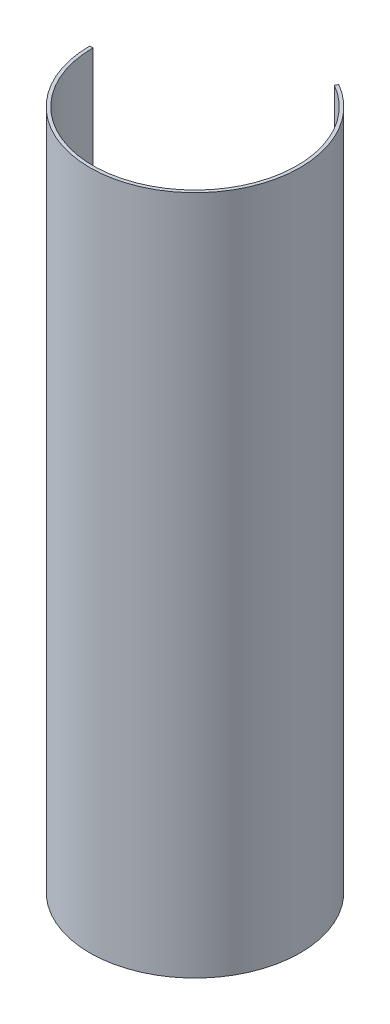
from build123d import *

# Parameters (mm, degrees)
SKETCH1_R           = 41.275
SKETCH1_R_2         = 40.005
BOSS_EXTRUDE1_DEPTH = 266.7
CUT_EXTRUDE3_DEPTH  = 267.7


with BuildPart() as part:
    # Sketch1 → Boss-Extrude1 (new body)
    with BuildSketch(Plane(origin=(0, 0, 0), x_dir=(1, 0, 0), z_dir=(0, 1, 0))):
        Circle(SKETCH1_R)
        Circle(SKETCH1_R_2, mode=Mode.SUBTRACT)
    extrude(amount=BOSS_EXTRUDE1_DEPTH)

    # Sketch3 → Cut-Extrude3 (cut, through all)
    with BuildSketch(Plane(origin=(0, 0, 0), x_dir=(1, 0, 0), z_dir=(0, 1, 0))):
        Polygon((0, 0), (-129.052842667, 0), (91.727456227, 158.876614634), align=None)
    extrude(amount=CUT_EXTRUDE3_DEPTH, mode=Mode.SUBTRACT)


solid = part.part
